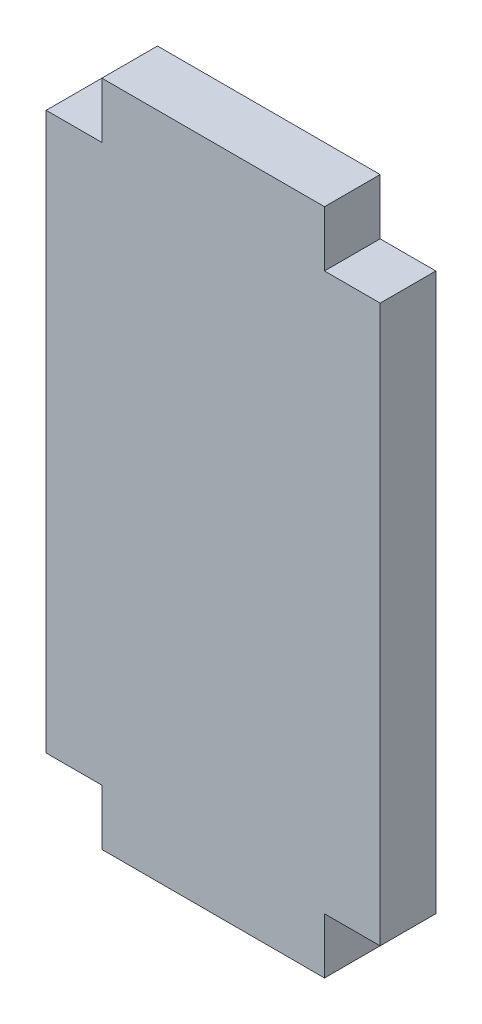
from build123d import *

# Parameters (mm, degrees)
BOSS_EXTRU_1_DEPTH = 5


with BuildPart() as part:
    # Esquisse1 → Boss.-Extru.1 (new body)
    with BuildSketch(Plane.XY):
        Polygon((28.598756905, 46.041666667), (33.598756905, 46.041666667), (33.598756905, 51.041666667), (53.598756905, 51.041666667), (53.598756905, 46.041666667), (58.598756905, 46.041666667), (58.598756905, -3.958333333), (53.598756905, -3.958333333), (53.598756905, -8.958333333), (33.598756905, -8.958333333), (33.598756905, -3.958333333), (28.598756905, -3.958333333), align=None)
    extrude(amount=BOSS_EXTRU_1_DEPTH)


solid = part.part
